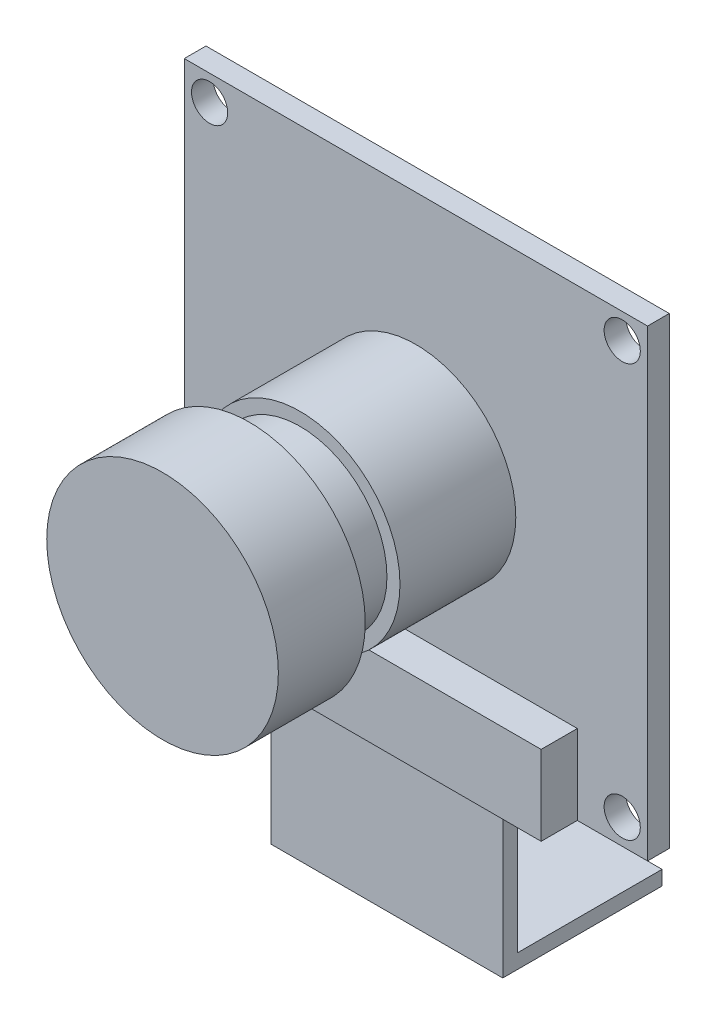
from build123d import *

# Parameters (mm, degrees)
SKETCH_1_W         = 32
SKETCH_1_H         = 32
SKETCH_1_R         = 1.25
EXTRUDE_1472_DEPTH = 1.5
EXTRUDE_START      = 1.5
SKETCH_1_3_W       = 22.3
SKETCH_1_3_H       = 5.5
EXTRUDE_1647_DEPTH = 2.5
SKETCH_1_4_R       = 6.9
SKETCH_1_4_R_2     = 6
EXTRUDE_1817_DEPTH = 8
EXTRUDE_START_2    = 9.5
SKETCH_1_5_R       = 6
EXTRUDE_1989_DEPTH = 3.5
EXTRUDE_START_3    = 13
SKETCH_1_6_R       = 8
SKETCH_1_6_R_2     = 6.9
SKETCH_1_6_R_3     = 6
EXTRUDE_2083_DEPTH = 6
SKETCH_1_7_R       = 1.5
EXTRUDE_2264_DEPTH = 0.5
SKETCH_2_W         = 16
SKETCH_2_H         = 1
EXTRUDE_2724_DEPTH = 10
SKETCH_3_W         = 16
SKETCH_3_H         = 1
EXTRUDE_3021_DEPTH = 10


with BuildPart() as part:
    # Эскиз1 → Extrude 1472 (new body)
    with BuildSketch(Plane.XY):
        Rectangle(SKETCH_1_W, SKETCH_1_H)
        with Locations((-14.25, -14.25)):
            Circle(SKETCH_1_R, mode=Mode.SUBTRACT)
        with Locations((14.25, -14.25)):
            Circle(SKETCH_1_R, mode=Mode.SUBTRACT)
        with Locations((-14.25, 14.25)):
            Circle(SKETCH_1_R, mode=Mode.SUBTRACT)
        with Locations((14.25, 14.25)):
            Circle(SKETCH_1_R, mode=Mode.SUBTRACT)
    extrude(amount=EXTRUDE_1472_DEPTH)

    # Эскиз1<3> → Extrude 1647 (add)
    with BuildSketch(Plane.XY.offset(EXTRUDE_START)):
        with Locations((0, -13.25)):
            Rectangle(SKETCH_1_3_W, SKETCH_1_3_H)
    extrude(amount=EXTRUDE_1647_DEPTH)

    # Эскиз1<4> → Extrude 1817 (add)
    with BuildSketch(Plane.XY.offset(EXTRUDE_START)):
        Circle(SKETCH_1_4_R)
        Circle(SKETCH_1_4_R_2, mode=Mode.SUBTRACT)
        Circle(SKETCH_1_4_R_2)
    extrude(amount=EXTRUDE_1817_DEPTH)

    # Эскиз1<5> → Extrude 1989 (add)
    with BuildSketch(Plane.XY.offset(EXTRUDE_START_2)):
        Circle(SKETCH_1_5_R)
    extrude(amount=EXTRUDE_1989_DEPTH)

    # Эскиз1<6> → Extrude 2083 (add)
    with BuildSketch(Plane.XY.offset(EXTRUDE_START_3)):
        Circle(SKETCH_1_6_R)
        Circle(SKETCH_1_6_R_2, mode=Mode.SUBTRACT)
        Circle(SKETCH_1_6_R_2)
        Circle(SKETCH_1_6_R_3, mode=Mode.SUBTRACT)
        Circle(SKETCH_1_6_R_3)
    extrude(amount=EXTRUDE_2083_DEPTH)

    # Эскиз1<7> → Extrude 2264 (add)
    with BuildSketch(Plane.XY):
        with Locations((9.5, 0)):
            Circle(SKETCH_1_7_R)
        with Locations((-9.5, 0)):
            Circle(SKETCH_1_7_R)
    extrude(amount=-EXTRUDE_2264_DEPTH)

    # Эскиз2 → Extrude 2724 (add)
    with BuildSketch(Plane.XZ.offset(16)):
        with Locations((0, 3)):
            Rectangle(SKETCH_2_W, SKETCH_2_H)
    extrude(amount=EXTRUDE_2724_DEPTH)

    # Эскиз3 → Extrude 3021 (add)
    with BuildSketch(Plane(origin=(0, 0, 2.5), x_dir=(-1, 0, 0), z_dir=(0, 0, -1))):
        with Locations((0, -25.5)):
            Rectangle(SKETCH_3_W, SKETCH_3_H)
    extrude(amount=EXTRUDE_3021_DEPTH)


solid = part.part
